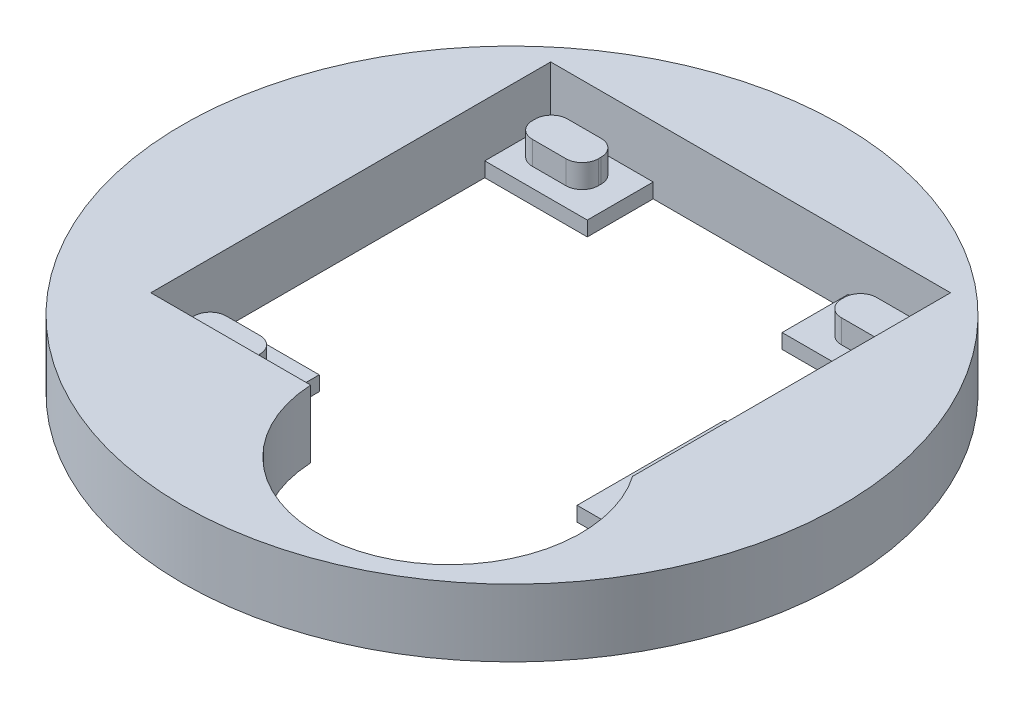
from build123d import *

# Parameters (mm, degrees)
SKETCH1_R           = 22.5
BOSS_EXTRUDE1_DEPTH = 3.6
BOSS_EXTRUDE2_START = -1
SKETCH1_3_R         = 22.5
BOSS_EXTRUDE2_DEPTH = 1
BOSS_EXTRUDE3_DEPTH = 1.6


with BuildPart() as part:
    # Sketch1 → Boss-Extrude1 (new body)
    with BuildSketch(Plane(origin=(0, 0, 0), x_dir=(1, 0, 0), z_dir=(0, 1, 0))):
        Circle(SKETCH1_R)
        with BuildLine():
            Line((-13.65, 11.790472541), (-13.65, 16.290472541))
            Line((-13.65, 16.290472541), (-6.65, 16.290472541))
            Line((-6.65, 16.290472541), (6.65, 16.290472541))
            Line((6.65, 16.290472541), (13.65, 16.290472541))
            Line((13.65, 16.290472541), (13.65, 11.790472541))
            Line((13.65, 11.790472541), (13.65, 4.642529479))
            Line((13.65, 4.642529479), (13.65, -5.41416329))
            ThreePointArc((13.65, -5.41416329), (13.652871179, -5.418313502), (13.65574003, -5.422465323))
            ThreePointArc((13.65574003, -5.422465323), (14.219560095, -14.718302537), (6.25, -19.53666268))
            ThreePointArc((6.25, -19.53666268), (0.055477541, -17.065666548), (-2.737569132, -11.009527459))
            Line((-2.737569132, -11.009527459), (-6.65, -11.009527459))
            Line((-6.65, -11.009527459), (-13.65, -11.009527459))
            Line((-13.65, -11.009527459), (-13.65, -6.509527459))
            Line((-13.65, -6.509527459), (-13.65, 11.790472541))
        make_face(mode=Mode.SUBTRACT)
    extrude(amount=BOSS_EXTRUDE1_DEPTH)

    # Sketch1_3 → Boss-Extrude2 (add)
    with BuildSketch(Plane(origin=(0, 0, 0), x_dir=(1, 0, 0), z_dir=(0, 1, 0)).offset(BOSS_EXTRUDE2_START)):
        Circle(SKETCH1_3_R)
        with BuildLine():
            Line((-6.65, 11.790472541), (-6.65, 16.290472541))
            Line((-6.65, 16.290472541), (6.65, 16.290472541))
            Line((6.65, 16.290472541), (6.65, 11.790472541))
            Line((6.65, 11.790472541), (13.65, 11.790472541))
            Line((13.65, 11.790472541), (13.65, 4.642529479))
            Line((13.65, 4.642529479), (9.867222257, 4.642529479))
            Line((9.867222257, 4.642529479), (9.867222257, -5.422465323))
            Line((9.867222257, -5.422465323), (13.65, -5.422465323))
            Line((13.65, -5.422465323), (13.65, -5.41416329))
            ThreePointArc((13.65, -5.41416329), (9.158112615, -19.053873551), (-2.737569132, -11.009527459))
            Line((-2.737569132, -11.009527459), (-6.65, -11.009527459))
            Line((-6.65, -11.009527459), (-6.65, -6.509527459))
            Line((-6.65, -6.509527459), (-13.65, -6.509527459))
            Line((-13.65, -6.509527459), (-13.65, 11.790472541))
            Line((-13.65, 11.790472541), (-6.65, 11.790472541))
        make_face(mode=Mode.SUBTRACT)
    extrude(amount=BOSS_EXTRUDE2_DEPTH)

    # Sketch2 → Boss-Extrude3 (add)
    with BuildSketch(Plane(origin=(0, 0, 0), x_dir=(1, 0, 0), z_dir=(0, 1, 0))):
        with BuildLine():
            Line((-11.7, 13.090472541), (-9.4, 13.090472541))
            ThreePointArc((-9.4, 13.090472541), (-8.622182541, 13.412655081), (-8.3, 14.190472541))
            Line((-8.3, 14.190472541), (-8.3, 14.390472541))
            ThreePointArc((-8.3, 14.390472541), (-8.622182541, 15.16829), (-9.4, 15.490472541))
            Line((-9.4, 15.490472541), (-11.7, 15.490472541))
            ThreePointArc((-11.7, 15.490472541), (-12.477817459, 15.16829), (-12.8, 14.390472541))
            Line((-12.8, 14.390472541), (-12.8, 14.190472541))
            ThreePointArc((-12.8, 14.190472541), (-12.477817459, 13.412655081), (-11.7, 13.090472541))
        make_face()
        with BuildLine():
            Line((-11.7, -10.209527459), (-9.4, -10.209527459))
            ThreePointArc((-9.4, -10.209527459), (-8.622182541, -9.887344919), (-8.3, -9.109527459))
            Line((-8.3, -9.109527459), (-8.3, -8.909527459))
            ThreePointArc((-8.3, -8.909527459), (-8.622182541, -8.13171), (-9.4, -7.809527459))
            Line((-9.4, -7.809527459), (-11.7, -7.809527459))
            ThreePointArc((-11.7, -7.809527459), (-12.477817459, -8.13171), (-12.8, -8.909527459))
            Line((-12.8, -8.909527459), (-12.8, -9.109527459))
            ThreePointArc((-12.8, -9.109527459), (-12.477817459, -9.887344919), (-11.7, -10.209527459))
        make_face()
        with BuildLine():
            Line((11.7, 15.490472541), (9.4, 15.490472541))
            ThreePointArc((9.4, 15.490472541), (8.622182541, 15.16829), (8.3, 14.390472541))
            Line((8.3, 14.390472541), (8.3, 14.190472541))
            ThreePointArc((8.3, 14.190472541), (8.622182541, 13.412655081), (9.4, 13.090472541))
            Line((9.4, 13.090472541), (11.7, 13.090472541))
            ThreePointArc((11.7, 13.090472541), (12.477817459, 13.412655081), (12.8, 14.190472541))
            Line((12.8, 14.190472541), (12.8, 14.390472541))
            ThreePointArc((12.8, 14.390472541), (12.477817459, 15.16829), (11.7, 15.490472541))
        make_face()
    extrude(amount=BOSS_EXTRUDE3_DEPTH)


solid = part.part
